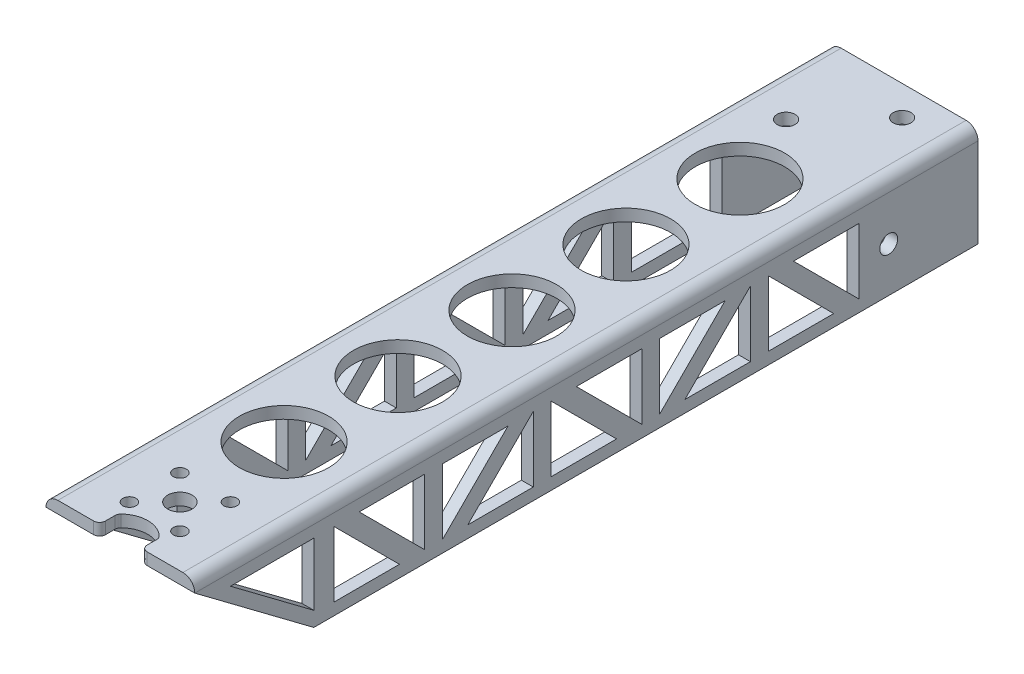
from build123d import *

# Parameters (mm, degrees)
BOSS_EXTRUDE1_DEPTH     = 20
SKETCH3_R               = 1.5
CUT_EXTRUDE1_DEPTH      = 1
CUT_EXTRUDE1_DEPTH_BACK = 2
SKETCH17_R              = 1.5
CUT_EXTRUDE13_DEPTH     = 2
SKETCH4_R               = 1.5
CUT_EXTRUDE2_DEPTH      = 1
CUT_EXTRUDE2_DEPTH_BACK = 18
BOSS_EXTRUDE2_DEPTH     = 111.6
SKETCH7_R               = 7.5
CUT_EXTRUDE3_DEPTH      = 18
LPATTERN1_COUNT         = 5
LPATTERN1_PITCH         = 19.15
SKETCH8_R               = 1.1
CUT_EXTRUDE4_DEPTH      = 18
CUT_EXTRUDE6_DEPTH      = 26
CUT_EXTRUDE7_DEPTH      = 26
CUT_EXTRUDE8_DEPTH      = 26
CUT_EXTRUDE9_DEPTH      = 26
CUT_EXTRUDE10_DEPTH     = 26
LPATTERN2_COUNT         = 3
LPATTERN2_PITCH         = 36.4853
LPATTERN3_COUNT         = 3
LPATTERN3_PITCH         = 36.4853
LPATTERN4_COUNT         = 2
LPATTERN4_PITCH         = 36.4853
LPATTERN5_COUNT         = 2
LPATTERN5_PITCH         = 36.4853
CUT_EXTRUDE11_DEPTH     = 26
SKETCH16_R              = 2.05
CUT_EXTRUDE12_DEPTH     = 18
SKETCH18_W              = 7
SKETCH18_H              = 3
CUT_EXTRUDE14_DEPTH     = 2
FILLET1_R               = 1


with BuildPart() as part:
    # Sketch1 → Boss-Extrude1 (new body)
    with BuildSketch(Plane.XY):
        with BuildLine():
            Line((-12.5, -8.5), (-10.5, -8.5))
            Line((-10.5, -8.5), (-10.5, 4.5))
            ThreePointArc((-10.5, 4.5), (-9.914213562, 5.914213562), (-8.5, 6.5))
            Line((-8.5, 6.5), (8.5, 6.5))
            ThreePointArc((8.5, 6.5), (9.914213562, 5.914213562), (10.5, 4.5))
            Line((10.5, 4.5), (10.5, -8.5))
            Line((10.5, -8.5), (12.5, -8.5))
            Line((12.5, -8.5), (12.5, 6.5))
            ThreePointArc((12.5, 6.5), (11.914213562, 7.914213562), (10.5, 8.5))
            Line((10.5, 8.5), (-10.5, 8.5))
            ThreePointArc((-10.5, 8.5), (-11.914213562, 7.914213562), (-12.5, 6.5))
            Line((-12.5, 6.5), (-12.5, -8.5))
        make_face()
    extrude(amount=BOSS_EXTRUDE1_DEPTH)

    # Sketch3 → Cut-Extrude1 (cut, two sides)
    with BuildSketch(Plane(origin=(12.5, 0, 0), x_dir=(0, 0, -1), z_dir=(1, 0, 0))) as cut_extrude1_sk:
        with Locations((-15, -1)):
            Circle(SKETCH3_R)
    extrude(amount=CUT_EXTRUDE1_DEPTH, mode=Mode.SUBTRACT)
    extrude(cut_extrude1_sk.sketch, amount=-CUT_EXTRUDE1_DEPTH_BACK, mode=Mode.SUBTRACT)

    # Sketch17 → Cut-Extrude13 (cut)
    with BuildSketch(Plane.ZY.offset(12.5)):
        with Locations((5, -1)):
            Circle(SKETCH17_R)
    extrude(amount=-CUT_EXTRUDE13_DEPTH, mode=Mode.SUBTRACT)

    # Sketch4 → Cut-Extrude2 (cut, two sides)
    with BuildSketch(Plane(origin=(0, 8.5, 0), x_dir=(1, 0, 0), z_dir=(0, 1, 0))) as cut_extrude2_sk:
        with Locations((-4.75, -15)):
            Circle(SKETCH4_R)
        with Locations((4.75, -5)):
            Circle(SKETCH4_R)
    extrude(amount=CUT_EXTRUDE2_DEPTH, mode=Mode.SUBTRACT)
    extrude(cut_extrude2_sk.sketch, amount=-CUT_EXTRUDE2_DEPTH_BACK, mode=Mode.SUBTRACT)

    # Sketch6 → Boss-Extrude2 (add)
    with BuildSketch(Plane.XY.offset(20)):
        with BuildLine():
            Line((-12.5, 6.5), (-12.5, -8.5))
            Line((-12.5, -8.5), (-10.5, -8.5))
            Line((-10.5, -8.5), (-10.5, 4.5))
            ThreePointArc((-10.5, 4.5), (-9.914213562, 5.914213562), (-8.5, 6.5))
            Line((-8.5, 6.5), (8.5, 6.5))
            ThreePointArc((8.5, 6.5), (9.914213562, 5.914213562), (10.5, 4.5))
            Line((10.5, 4.5), (10.5, -8.5))
            Line((10.5, -8.5), (12.5, -8.5))
            Line((12.5, -8.5), (12.5, 6.5))
            ThreePointArc((12.5, 6.5), (11.914213562, 7.914213562), (10.5, 8.5))
            Line((10.5, 8.5), (-10.5, 8.5))
            ThreePointArc((-10.5, 8.5), (-11.914213562, 7.914213562), (-12.5, 6.5))
        make_face()
    extrude(amount=BOSS_EXTRUDE2_DEPTH)

    # Sketch7 → Cut-Extrude3 (cut, through all)
    with BuildSketch(Plane(origin=(0, 8.5, 0), x_dir=(1, 0, 0), z_dir=(0, 1, 0))):
        with Locations((0, -104.1)):
            Circle(SKETCH7_R)
    cut_extrude3 = extrude(amount=-CUT_EXTRUDE3_DEPTH, mode=Mode.SUBTRACT)

    # LPattern1: Cut-Extrude3 ×5
    with Locations(*[(0, 0, -i * LPATTERN1_PITCH) for i in range(1, LPATTERN1_COUNT)]):
        add(cut_extrude3, mode=Mode.SUBTRACT)

    # Sketch8 → Cut-Extrude4 (cut, through all)
    with BuildSketch(Plane(origin=(0, 8.5, 0), x_dir=(1, 0, 0), z_dir=(0, 1, 0))):
        with Locations((4.242640687, -117.357359313)):
            Circle(SKETCH8_R)
        with Locations((4.242640687, -125.842640687)):
            Circle(SKETCH8_R)
        with Locations((-4.242640687, -125.842640687)):
            Circle(SKETCH8_R)
        with Locations((-4.242640687, -117.357359313)):
            Circle(SKETCH8_R)
    extrude(amount=-CUT_EXTRUDE4_DEPTH, mode=Mode.SUBTRACT)

    # Sketch9 → Cut-Extrude6 (cut, through all)
    with BuildSketch(Plane(origin=(12.5, 0, 0), x_dir=(0, 0, -1), z_dir=(1, 0, 0))):
        Polygon((-131.6, 6.5), (-111.6, -8.5), (-131.6, -8.5), align=None)
    extrude(amount=-CUT_EXTRUDE6_DEPTH, mode=Mode.SUBTRACT)

    # Sketch10 → Cut-Extrude7 (cut, through all)
    with BuildSketch(Plane(origin=(12.5, 0, 0), x_dir=(0, 0, -1), z_dir=(1, 0, 0))):
        Polygon((-31, 4.5), (-20, 4.5), (-20, -6.5), align=None)
    cut_extrude7 = extrude(amount=-CUT_EXTRUDE7_DEPTH, mode=Mode.SUBTRACT)

    # Sketch11 → Cut-Extrude8 (cut, through all)
    with BuildSketch(Plane(origin=(12.5, 0, 0), x_dir=(0, 0, -1), z_dir=(1, 0, 0))):
        Polygon((-35.242640687, 4.5), (-24.242640687, -6.5), (-35.242640687, -6.5), align=None)
    cut_extrude8 = extrude(amount=-CUT_EXTRUDE8_DEPTH, mode=Mode.SUBTRACT)

    # Sketch12 → Cut-Extrude9 (cut, through all)
    with BuildSketch(Plane(origin=(12.5, 0, 0), x_dir=(0, 0, -1), z_dir=(1, 0, 0))):
        Polygon((-38.242640687, 4.5), (-38.242640687, -6.5), (-49.242640687, -6.5), align=None)
    cut_extrude9 = extrude(amount=-CUT_EXTRUDE9_DEPTH, mode=Mode.SUBTRACT)

    # Sketch13 → Cut-Extrude10 (cut, through all)
    with BuildSketch(Plane(origin=(12.5, 0, 0), x_dir=(0, 0, -1), z_dir=(1, 0, 0))):
        Polygon((-53.485281374, -6.5), (-42.485281374, 4.5), (-53.485281374, 4.5), align=None)
    cut_extrude10 = extrude(amount=-CUT_EXTRUDE10_DEPTH, mode=Mode.SUBTRACT)

    # LPattern2: Cut-Extrude7 ×3
    with Locations(*[(0, 0, i * LPATTERN2_PITCH) for i in range(1, LPATTERN2_COUNT)]):
        add(cut_extrude7, mode=Mode.SUBTRACT)

    # LPattern3: Cut-Extrude8 ×3
    with Locations(*[(0, 0, i * LPATTERN3_PITCH) for i in range(1, LPATTERN3_COUNT)]):
        add(cut_extrude8, mode=Mode.SUBTRACT)

    # LPattern4: Cut-Extrude9 ×2
    with Locations(*[(0, 0, i * LPATTERN4_PITCH) for i in range(1, LPATTERN4_COUNT)]):
        add(cut_extrude9, mode=Mode.SUBTRACT)

    # LPattern5: Cut-Extrude10 ×2
    with Locations(*[(0, 0, i * LPATTERN5_PITCH) for i in range(1, LPATTERN5_COUNT)]):
        add(cut_extrude10, mode=Mode.SUBTRACT)

    # Sketch14 → Cut-Extrude11 (cut, through all)
    with BuildSketch(Plane(origin=(12.5, 0, 0), x_dir=(0, 0, -1), z_dir=(1, 0, 0))):
        Polygon((-111.6, -6), (-111.6, 4.5), (-125.6, 4.5), align=None)
    extrude(amount=-CUT_EXTRUDE11_DEPTH, mode=Mode.SUBTRACT)

    # Sketch16 → Cut-Extrude12 (cut, through all)
    with BuildSketch(Plane(origin=(0, 8.5, 0), x_dir=(1, 0, 0), z_dir=(0, 1, 0))):
        with Locations((0, -121.6)):
            Circle(SKETCH16_R)
    extrude(amount=-CUT_EXTRUDE12_DEPTH, mode=Mode.SUBTRACT)

    # Sketch18 → Cut-Extrude14 (cut)
    with BuildSketch(Plane(origin=(0, 8.5, 0), x_dir=(1, 0, 0), z_dir=(0, 1, 0))):
        with BuildLine():
            ThreePointArc((-3.5, -128.6), (0, -126.990227771), (3.5, -128.6))
            Line((3.5, -128.6), (-3.5, -128.6))
        make_face()
        with Locations((0, -130.1)):
            Rectangle(SKETCH18_W, SKETCH18_H)
    extrude(amount=-CUT_EXTRUDE14_DEPTH, mode=Mode.SUBTRACT)

    # Fillet1
    fillet1_edges = [part.edges().sort_by_distance(p)[0] for p in [
        (-3.5, 7.5, 131.6),
        (3.5, 7.5, 131.6),
        (3.5, 7.5, 128.6),
        (-3.5, 7.5, 128.6),
    ]]
    fillet(fillet1_edges, radius=FILLET1_R)


solid = part.part
